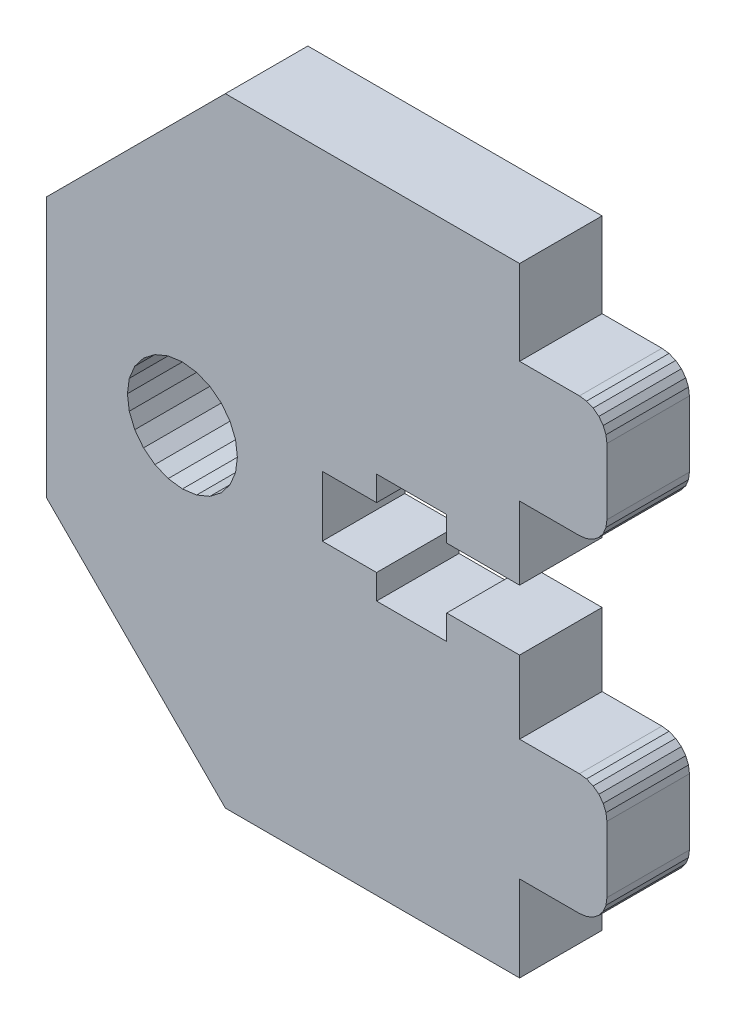
from build123d import *

# Parameters (mm, degrees)
BOSS_EXTRUDE1_DEPTH = 6


with BuildPart() as part:
    # Sketch1 → Boss-Extrude1 (new body)
    with BuildSketch(Plane.XY):
        Polygon((57.062796569, -307.643524718), (44.062799449, -320.643521838), (44.062799449, -339.603497029), (57.062796569, -352.643507118), (78.462791321, -352.643507118), (78.462791321, -346.403487337), (82.812789212, -346.403487337), (83.330427302, -346.33533899), (83.812789212, -346.135538145), (84.227002775, -345.8177009), (84.54484002, -345.403487337), (84.744640865, -344.921125427), (84.812789212, -344.403487337), (84.812789212, -339.603491372), (84.744640865, -339.085853282), (84.54484002, -338.603491372), (84.227002775, -338.18927781), (83.812789212, -337.871440565), (83.330427302, -337.67163972), (82.812789212, -337.603491372), (78.462791321, -337.603491372), (78.462791321, -332.303499365), (73.162792499, -332.303499365), (73.162792499, -334.103497597), (68.062794735, -334.103497597), (68.062794735, -332.303499365), (64.112794912, -332.303499365), (64.112794912, -327.903494694), (68.062794735, -327.903494694), (68.062794735, -326.103496462), (73.162792499, -326.103496462), (73.162792499, -327.903494694), (78.462791321, -327.903494694), (78.462791321, -322.603497439), (82.812789212, -322.603497439), (83.330427302, -322.535349091), (83.812789212, -322.335548246), (84.227002775, -322.017711001), (84.54484002, -321.603497439), (84.744640865, -321.121135529), (84.812789212, -320.603497439), (84.812789212, -315.803502996), (84.744640865, -315.285864906), (84.54484002, -314.803502996), (84.227002775, -314.389289434), (83.812789212, -314.071452189), (83.330427302, -313.871651344), (82.812789212, -313.803502996), (78.462791321, -313.803502996), (78.462791321, -307.643524718), align=None)
        Polygon((49.940071687, -330.103497029), (50.076368382, -331.13877321), (50.475970072, -332.103497029), (51.111644562, -332.931924154), (51.940071687, -333.567598645), (52.904795507, -333.967200335), (53.940071687, -334.103497029), (54.975347868, -333.967200335), (55.940071687, -333.567598645), (56.768498812, -332.931924154), (57.404173302, -332.103497029), (57.803774992, -331.13877321), (57.940071687, -330.103497029), (57.803774992, -329.068220849), (57.404173302, -328.103497029), (56.768498812, -327.275069905), (55.940071687, -326.639395414), (54.975347868, -326.239793724), (53.940071687, -326.103497029), (52.904795507, -326.239793724), (51.940071687, -326.639395414), (51.111644562, -327.275069905), (50.475970072, -328.103497029), (50.076368382, -329.068220849), align=None, mode=Mode.SUBTRACT)
    extrude(amount=BOSS_EXTRUDE1_DEPTH)


solid = part.part
